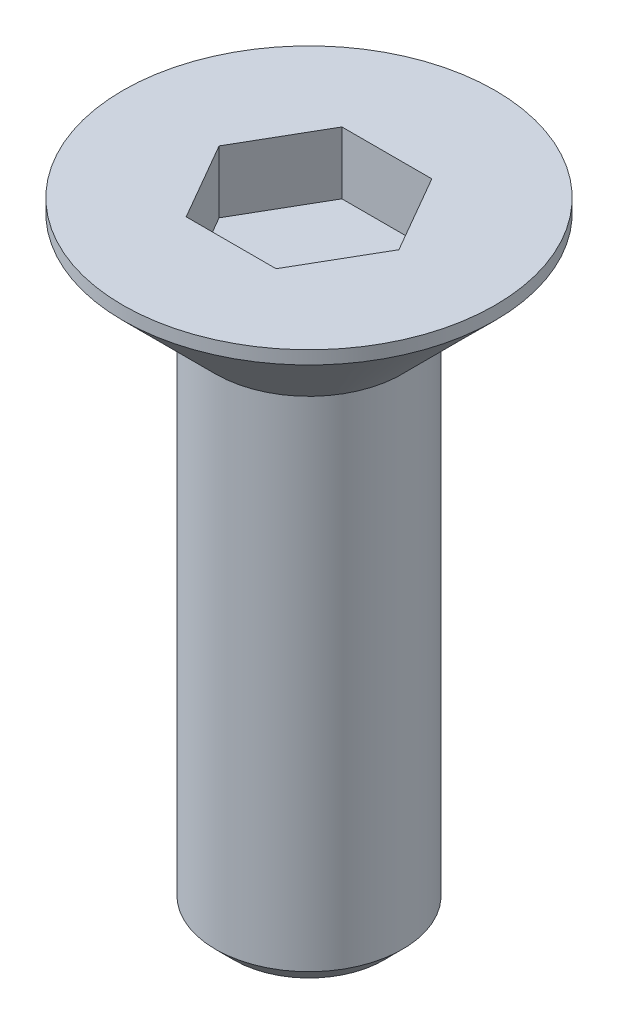
from build123d import *

# Parameters (mm, degrees)
CHAFL_N2_SIZE         = 0.3
CHAFL_N2_SIZE2        = 0.212132034
CHAFL_N3_SIZE         = 0.3
CORTAR_EXTRUIR2_DEPTH = 1


with BuildPart() as part:
    # Croquis1 → Revolución1 (revolve)
    with BuildSketch(Plane.XY, mode=Mode.PRIVATE) as revoluci_n1_sk:
        Polygon((0, 0), (3.2, 0), (1.5, -1.7), (1.5, -10), (0, -10), align=None)
    revolve(revoluci_n1_sk.sketch.rotate(Axis((0, 0, 0), (0, -1, 0)), 90), axis=Axis((0, 0, 0), (0, -1, 0)))

    # Chaflán2
    chafl_n2_edges = [part.edges().sort_by_distance(p)[0] for p in [
        (0, 0, -3.2),
    ]]
    chafl_n2_side = [part.faces().sort_by_distance(p)[0] for p in [
        (0, -0.85, -2.35),
    ]]
    chamfer(chafl_n2_edges, length=CHAFL_N2_SIZE, length2=CHAFL_N2_SIZE2, reference=chafl_n2_side[0])

    # Chaflán3
    chafl_n3_edges = [part.edges().sort_by_distance(p)[0] for p in [
        (0, -10, -1.5),
    ]]
    chamfer(chafl_n3_edges, length=CHAFL_N3_SIZE)

    # Croquis3 → Cortar-Extruir2 (cut)
    with BuildSketch(Plane(origin=(0, 0, 0), x_dir=(1, 0, 0), z_dir=(0, 1, 0))):
        Polygon((-0.721687836, 1.25), (-1.443375673, 0), (-0.721687836, -1.25), (0.721687836, -1.25), (1.443375673, 0), (0.721687836, 1.25), align=None)
    extrude(amount=-CORTAR_EXTRUIR2_DEPTH, mode=Mode.SUBTRACT)


solid = part.part
